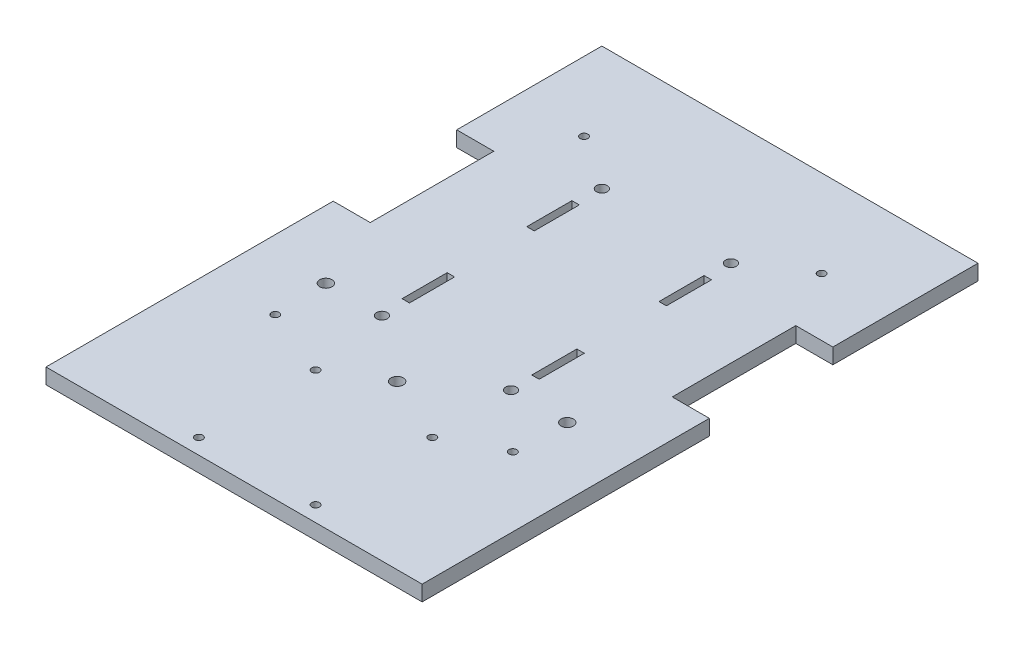
from build123d import *

# Parameters (mm, degrees)
SKETCH2_W           = 154.686
SKETCH2_H           = 228.6
BOSS_EXTRUDE1_DEPTH = 6.35
SKETCH1_R           = 2.2225
CUT_EXTRUDE1_DEPTH  = 6.35
SKETCH3_W           = 15.24
SKETCH3_H           = 50.8
CUT_EXTRUDE2_DEPTH  = 6.35
SKETCH8_R           = 2.54
CUT_EXTRUDE3_DEPTH  = 17.78
SKETCH9_R           = 1.5875
CUT_EXTRUDE4_DEPTH  = 17.78
SKETCH10_R          = 1.5875
CUT_EXTRUDE5_DEPTH  = 10.16
SKETCH12_W          = 3.048
SKETCH12_H          = 18.542
CUT_EXTRUDE7_DEPTH  = 8.255


with BuildPart() as part:
    # Sketch2 → Boss-Extrude1 (new body)
    with BuildSketch(Plane(origin=(0, 0, 0), x_dir=(1, 0, 0), z_dir=(0, 1, 0))):
        with Locations((26.543, 26.944051327)):
            Rectangle(SKETCH2_W, SKETCH2_H)
    extrude(amount=BOSS_EXTRUDE1_DEPTH)

    # Sketch1 → Cut-Extrude1 (cut)
    with BuildSketch(Plane(origin=(0, 0, 0), x_dir=(1, 0, 0), z_dir=(0, 1, 0))):
        with Locations((0, 90.444051327)):
            Circle(SKETCH1_R)
        with Locations((53.086, 90.444051327)):
            Circle(SKETCH1_R)
        Circle(SKETCH1_R)
        with Locations((53.086, 0)):
            Circle(SKETCH1_R)
    extrude(amount=CUT_EXTRUDE1_DEPTH, mode=Mode.SUBTRACT)

    # Sketch3 → Cut-Extrude2 (cut)
    with BuildSketch(Plane(origin=(0, 6.35, 0), x_dir=(1, 0, 0), z_dir=(0, 1, 0))):
        with Locations((96.266, 56.154051327)):
            Rectangle(SKETCH3_W, SKETCH3_H)
        with Locations((-43.18, 56.154051327)):
            Rectangle(SKETCH3_W, SKETCH3_H)
    extrude(amount=-CUT_EXTRUDE2_DEPTH, mode=Mode.SUBTRACT)

    # Sketch8 → Cut-Extrude3 (cut)
    with BuildSketch(Plane(origin=(0, 6.35, 0), x_dir=(1, 0, 0), z_dir=(0, 1, 0))):
        with Locations((26.550112, -20.29968)):
            Circle(SKETCH8_R)
        with Locations((-23.077082804, 0.02032)):
            Circle(SKETCH8_R)
        with Locations((76.177306804, 0.02032)):
            Circle(SKETCH8_R)
    extrude(amount=-CUT_EXTRUDE3_DEPTH, mode=Mode.SUBTRACT)

    # Sketch9 → Cut-Extrude4 (cut)
    with BuildSketch(Plane(origin=(0, 6.35, 0), x_dir=(1, 0, 0), z_dir=(0, 1, 0))):
        with Locations((53.722112, -33.005948673)):
            Circle(SKETCH9_R)
        with Locations((5.722112, -33.005948673)):
            Circle(SKETCH9_R)
        with Locations((53.722112, -81.005948673)):
            Circle(SKETCH9_R)
        with Locations((5.722112, -81.005948673)):
            Circle(SKETCH9_R)
    extrude(amount=-CUT_EXTRUDE4_DEPTH, mode=Mode.SUBTRACT)

    # Sketch10 → Cut-Extrude5 (cut)
    with BuildSketch(Plane(origin=(0, 6.35, 0), x_dir=(1, 0, 0), z_dir=(0, 1, 0))):
        with Locations((-22.3266, 105.430051327)):
            Circle(SKETCH10_R)
        with Locations((-22.3266, -21.569948673)):
            Circle(SKETCH10_R)
        with Locations((75.4126, 105.430051327)):
            Circle(SKETCH10_R)
        with Locations((75.4126, -21.569948673)):
            Circle(SKETCH10_R)
    extrude(amount=-CUT_EXTRUDE5_DEPTH, mode=Mode.SUBTRACT)

    # Sketch12 → Cut-Extrude7 (cut)
    with BuildSketch(Plane(origin=(0, 6.35, 0), x_dir=(1, 0, 0), z_dir=(0, 1, 0))):
        with Locations((-0.373888, 19.451051327)):
            Rectangle(SKETCH12_W, SKETCH12_H)
        with Locations((-0.373888, 70.759051327)):
            Rectangle(SKETCH12_W, SKETCH12_H)
        with Locations((53.474112, 71.267051327)):
            Rectangle(SKETCH12_W, SKETCH12_H)
        with Locations((53.474112, 18.943051327)):
            Rectangle(SKETCH12_W, SKETCH12_H)
    extrude(amount=-CUT_EXTRUDE7_DEPTH, mode=Mode.SUBTRACT)


solid = part.part
